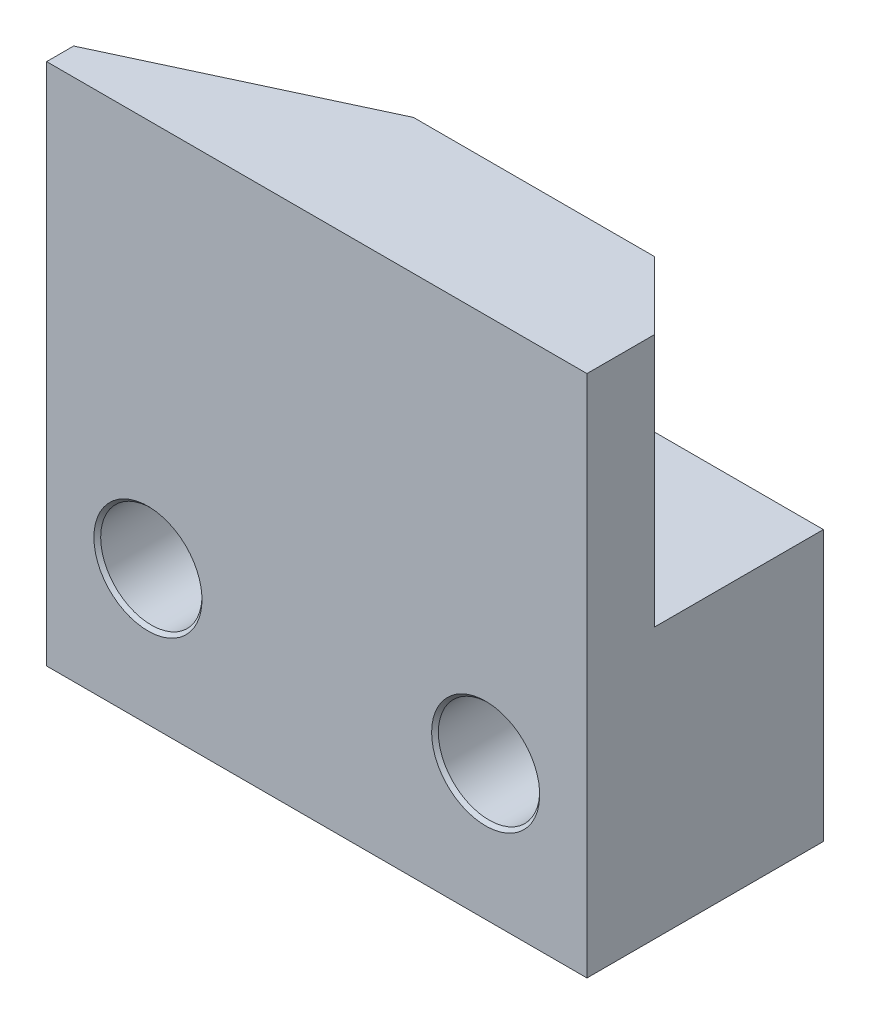
from build123d import *

# Parameters (mm, degrees)
SKETCH_1_W          = 16
SKETCH_1_H          = 7
EXTRUDE_1_DEPTH     = 15.5
CUT_EXTRUDE_1_DEPTH = 7.5
M3X0_51_AT_2_COUNT  = 2
M3X0_51_AT_2_PITCH  = 10


with BuildPart() as part:
    # Эскиз1 → Бобышка-Вытянуть1 (new body)
    with BuildSketch(Plane(origin=(0, 0, 0), x_dir=(1, 0, 0), z_dir=(0, 1, 0))):
        with Locations((8, 3.5)):
            Rectangle(SKETCH_1_W, SKETCH_1_H)
    extrude(amount=EXTRUDE_1_DEPTH)

    # Эскиз2 → Вырез-Вытянуть1 (cut)
    with BuildSketch(Plane(origin=(0, 15.5, 0), x_dir=(1, 0, 0), z_dir=(0, 1, 0))):
        Polygon((-40.166209025, -17.929810867), (0, 0.8), (6.862422146, 4), (14, 4), (16, 2), (47.337917628, -29.337917628), (58.796749642, 58.555289271), (-28.70737701, 69.963396032), align=None)
    extrude(amount=-CUT_EXTRUDE_1_DEPTH, mode=Mode.SUBTRACT)

    # Эскиз3 → Отверстие обработанное метчиком M3x0.51 (revolve, cut)
    with BuildSketch(Plane(origin=(3, 4, -7), x_dir=(0, 1, 0), z_dir=(1, 0, 0))):
        Polygon((0, 0), (0, 7), (1.6, 7), (1.5, 6.9), (1.5, 0.1), (1.6, 0), align=None)
    m3x0_51 = revolve(axis=Axis((3, 4, -13.35), (0, 0, 1)), mode=Mode.SUBTRACT)

    # Отверстие обработанное метчиком M3x0.51 at 2: Отверстие обработанное метчиком M3x0.51 ×2
    with Locations(*[(i * M3X0_51_AT_2_PITCH, 0, 0) for i in range(1, M3X0_51_AT_2_COUNT)]):
        add(m3x0_51, mode=Mode.SUBTRACT)


solid = part.part
